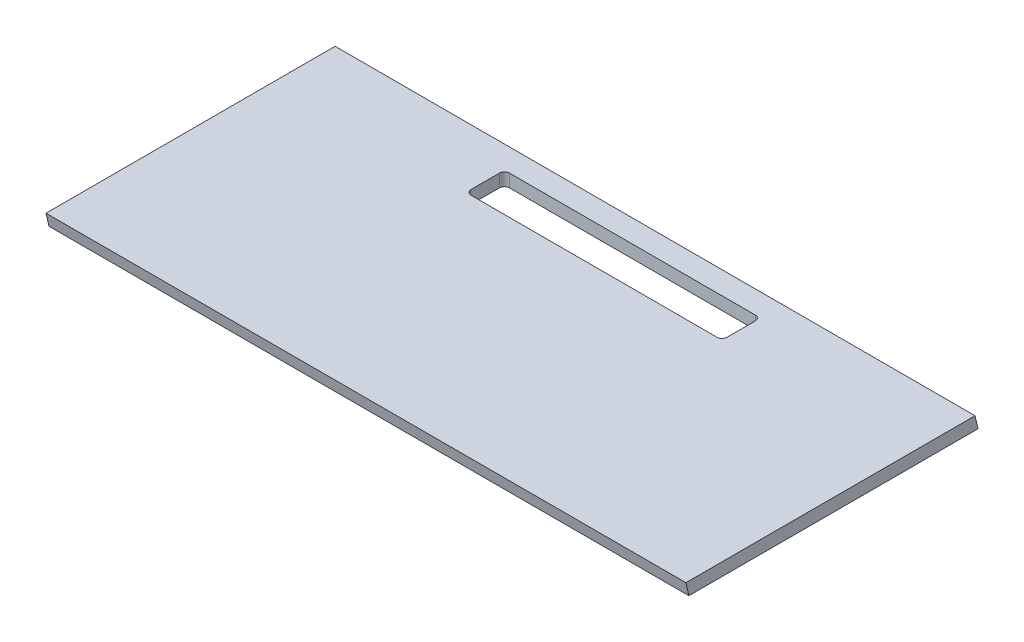
from build123d import *

# Parameters (mm, degrees)
SKETCH2_W           = 500
SKETCH2_H           = 228.2
BOSS_EXTRUDE1_DEPTH = 10
SKETCH3_W           = 200
SKETCH3_H           = 30
CUT_EXTRUDE1_DEPTH  = 10
FILLET1_R           = 4
CUT_EXTRUDE2_REACH  = 502


with BuildPart() as part:
    # Sketch2 → Boss-Extrude1 (new body)
    with BuildSketch(Plane(origin=(0, 0, 0), x_dir=(1, 0, 0), z_dir=(0, 1, 0))):
        Rectangle(SKETCH2_W, SKETCH2_H)
    extrude(amount=BOSS_EXTRUDE1_DEPTH)

    # Sketch3 → Cut-Extrude1 (cut)
    with BuildSketch(Plane(origin=(0, 10, 0), x_dir=(1, 0, 0), z_dir=(0, 1, 0))):
        with Locations((0, 79.1)):
            Rectangle(SKETCH3_W, SKETCH3_H)
    extrude(amount=-CUT_EXTRUDE1_DEPTH, mode=Mode.SUBTRACT)

    # Fillet1
    fillet1_edges = [part.edges().sort_by_distance(p)[0] for p in [
        (100, 5, -94.1),
        (100, 5, -64.1),
        (-100, 5, -64.1),
        (-100, 5, -94.1),
    ]]
    fillet(fillet1_edges, radius=FILLET1_R)

    # Sketch4 → Cut-Extrude2 (cut, up to next)
    with BuildSketch(Plane(origin=(250, 0, 0), x_dir=(0, 0, -1), z_dir=(1, 0, 0)), mode=Mode.PRIVATE) as cut_extrude2_sk1:
        Polygon((114.1, 0), (111.791318089, 10), (114.1, 10), align=None)
    cut_extrude2_tool1 = extrude(cut_extrude2_sk1.sketch, amount=-CUT_EXTRUDE2_REACH, mode=Mode.PRIVATE) & part.part
    add(cut_extrude2_tool1.solids().sort_by_distance((250, 6.666667, -113.330439))[0], mode=Mode.SUBTRACT)
    # Sketch4 → Cut-Extrude2 (cut, up to next)
    with BuildSketch(Plane(origin=(250, 0, 0), x_dir=(0, 0, -1), z_dir=(1, 0, 0)), mode=Mode.PRIVATE) as cut_extrude2_sk2:
        Polygon((-114.1, 0), (-114.1, 10), (-111.791318089, 0), align=None)
    cut_extrude2_tool2 = extrude(cut_extrude2_sk2.sketch, amount=-CUT_EXTRUDE2_REACH, mode=Mode.PRIVATE) & part.part
    add(cut_extrude2_tool2.solids().sort_by_distance((250, 3.333333, 113.330439))[0], mode=Mode.SUBTRACT)


solid = part.part
